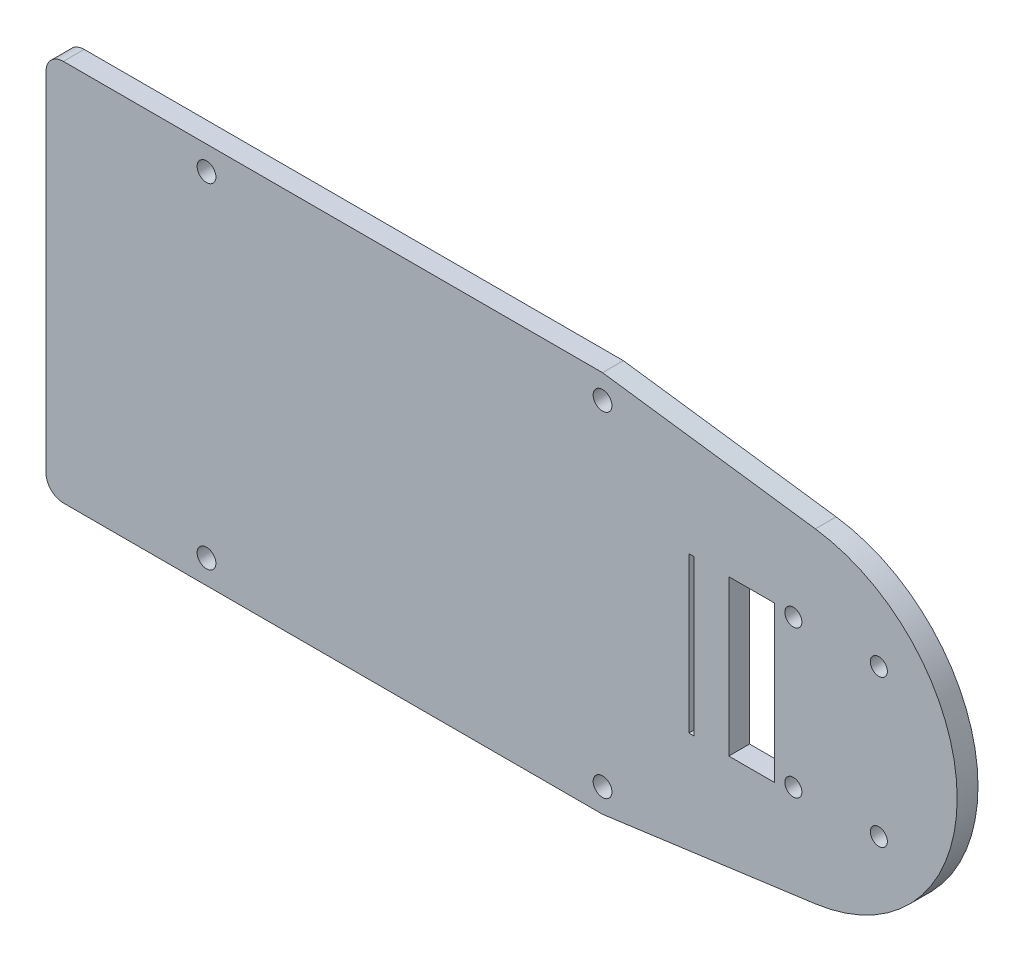
from build123d import *

# Parameters (mm, degrees)
SKETCH1_R           = 1.37499852
BOSS_EXTRUDE1_DEPTH = 3.048
SKETCH2_R           = 1.25
SKETCH2_W           = 6.7
SKETCH2_H           = 22.7542
SKETCH2_W_2         = 0.762
CUT_EXTRUDE1_DEPTH  = 4.048
SKETCH3_R           = 1.37499852
BOSS_EXTRUDE2_DEPTH = 3.048
CUT_EXTRUDE3_DEPTH  = 4.048


with BuildPart() as part:
    # Sketch1 → Boss-Extrude1 (new body)
    with BuildSketch(Plane.XY):
        with BuildLine():
            Line((0.41036367, 15.02963974), (60.10036367, 15.02963974))
            ThreePointArc((60.10036367, 15.02963974), (61.896414894, 14.285690964), (62.64036367, 12.48963974))
            Line((62.64036367, 12.48963974), (62.64036367, -38.4396361))
            ThreePointArc((62.64036367, -38.4396361), (61.896414894, -40.235687324), (60.10036367, -40.9796361))
            Line((60.10036367, -40.9796361), (0.41036367, -40.9796361))
            ThreePointArc((0.41036367, -40.9796361), (-1.385687554, -40.235687324), (-2.12963633, -38.4396361))
            Line((-2.12963633, -38.4396361), (-2.12963633, 12.48963974))
            ThreePointArc((-2.12963633, 12.48963974), (-1.385687554, 14.285690964), (0.41036367, 15.02963974))
        make_face()
        with Locations((1.37500106, 11.52500108)):
            Circle(SKETCH1_R, mode=Mode.SUBTRACT)
        with Locations((59.3750019, 11.52500108)):
            Circle(SKETCH1_R, mode=Mode.SUBTRACT)
        with Locations((59.3750019, -37.47499998)):
            Circle(SKETCH1_R, mode=Mode.SUBTRACT)
        with Locations((1.37500106, -37.47499998)):
            Circle(SKETCH1_R, mode=Mode.SUBTRACT)
    extrude(amount=-BOSS_EXTRUDE1_DEPTH)

    # Sketch2 → Cut-Extrude1 (cut, through all)
    with BuildSketch(Plane.XY):
        with Locations((29.315152151, -2.00169818)):
            Circle(SKETCH2_R)
        with Locations((41.838752151, -2.00169818)):
            Circle(SKETCH2_R)
        with Locations((41.838752151, -23.57459818)):
            Circle(SKETCH2_R)
        with Locations((29.315152151, -23.57459818)):
            Circle(SKETCH2_R)
        with Locations((23.210252151, -12.97499818)):
            Rectangle(SKETCH2_W, SKETCH2_H)
        with Locations((14.399252151, -12.97499818)):
            Rectangle(SKETCH2_W_2, SKETCH2_H)
    extrude(amount=-CUT_EXTRUDE1_DEPTH, mode=Mode.SUBTRACT)

    # Sketch3 → Boss-Extrude2 (add, through all)
    with BuildSketch(Plane.XY):
        with BuildLine():
            Line((-80.129638806, 12.489638674), (-80.129638806, -38.439637166))
            ThreePointArc((-80.129638806, -38.439637166), (-79.38569003, -40.23568839), (-77.589638806, -40.979637166))
            Line((-77.589638806, -40.979637166), (2.339634914, -40.979637166))
            ThreePointArc((2.339634914, -40.979637166), (4.135686138, -40.23568839), (4.879634914, -38.439637166))
            Line((4.879634914, -38.439637166), (4.879634914, 12.489638674))
            ThreePointArc((4.879634914, 12.489638674), (4.135686138, 14.285689898), (2.339634914, 15.029638674))
            Line((2.339634914, 15.029638674), (-77.589638806, 15.029638674))
            ThreePointArc((-77.589638806, 15.029638674), (-79.38569003, 14.285689898), (-80.129638806, 12.489638674))
        make_face()
        with Locations((1.37500106, -37.47499998)):
            Circle(SKETCH3_R, mode=Mode.SUBTRACT)
        with Locations((-56.62499978, -37.47499998)):
            Circle(SKETCH3_R, mode=Mode.SUBTRACT)
        with Locations((-56.62499978, 11.52500108)):
            Circle(SKETCH3_R, mode=Mode.SUBTRACT)
        with Locations((1.37500106, 11.52500108)):
            Circle(SKETCH3_R, mode=Mode.SUBTRACT)
    extrude(amount=-BOSS_EXTRUDE2_DEPTH)

    # Sketch5 → Cut-Extrude3 (cut, through all)
    with BuildSketch(Plane(origin=(0, 0, -3.048), x_dir=(-1, 0, 0), z_dir=(0, 0, -1))):
        with BuildLine():
            Line((-1.37500106, 15.02963974), (-32.538255274, 10.806103009))
            ThreePointArc((-32.538255274, 10.806103009), (-53.314152149, -12.975840892), (-32.537536563, -36.757156908))
            Line((-32.537536563, -36.757156908), (-1.37500106, -40.979637166))
            Line((-1.37500106, -40.979637166), (-97.655992842, -40.979637166))
            Line((-97.655992842, -40.979637166), (-97.655992842, 15.02963974))
            Line((-97.655992842, 15.02963974), (-1.37500106, 15.02963974))
        make_face()
    extrude(amount=-CUT_EXTRUDE3_DEPTH, mode=Mode.SUBTRACT)


solid = part.part
